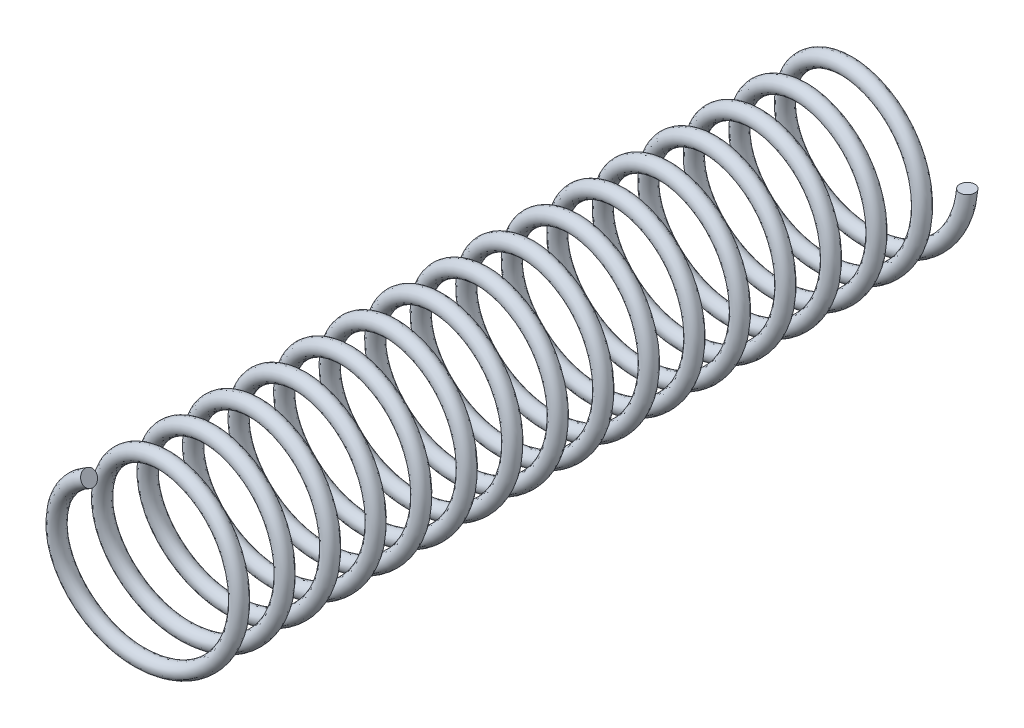
from build123d import *

# Parameters (mm, degrees)
VARREDURA3_PITCH  = 0.6
VARREDURA3_HEIGHT = 10
VARREDURA3_RADIUS = 1.05
ESBO_O3_R         = 0.1


with BuildPart() as part:
    # Varredura3: sweep along a helix
    with BuildLine() as varredura3_path:
        Helix(VARREDURA3_PITCH, VARREDURA3_HEIGHT, VARREDURA3_RADIUS, center=(0, 0, 0), direction=(0, 0, 1), lefthand=True)
    # Esboço3 → Varredura3 (sweep)
    with BuildSketch(Plane(origin=(0, 0, 0), x_dir=(0, 0, -1), z_dir=(1, 0, 0))):
        with Locations((-9.450000584, 1.049940706)):
            Circle(ESBO_O3_R)
    sweep(path=varredura3_path.line, is_frenet=True)


solid = part.part
